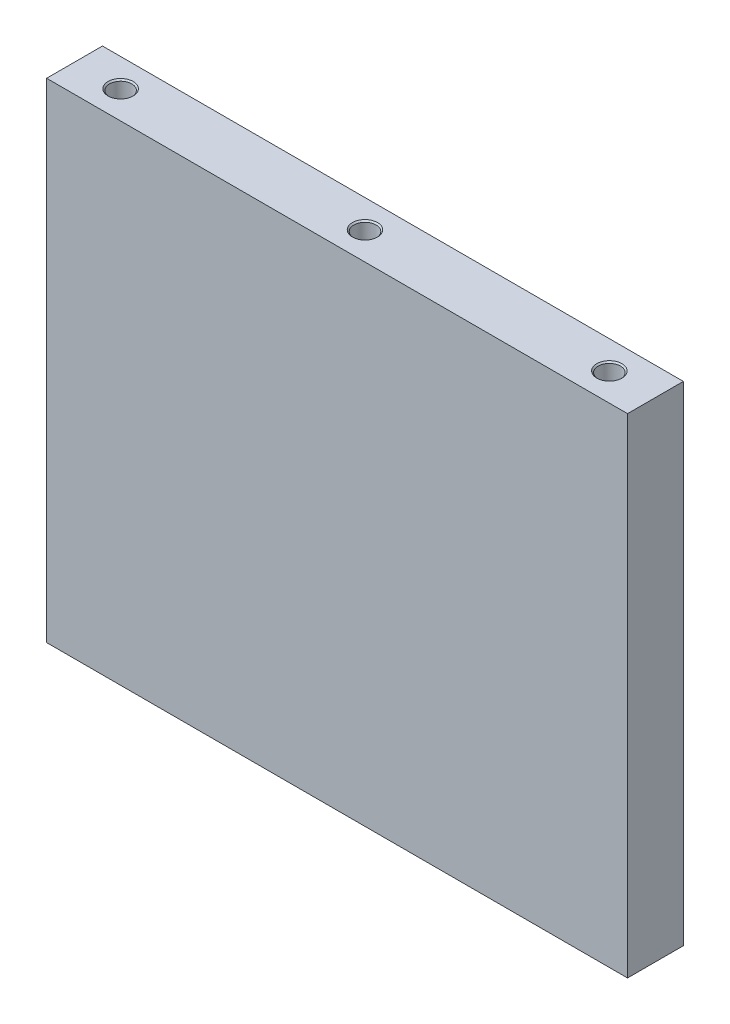
from build123d import *

# Parameters (mm, degrees)
SKETCH1_W           = 208
SKETCH1_H           = 20
BOSS_EXTRUDE1_DEPTH = 175
SKETCH2_R           = 4
CUT_EXTRUDE1_DEPTH  = 12
CHAMFER1_SIZE       = 0.5


with BuildPart() as part:
    # Sketch1 → Boss-Extrude1 (new body)
    with BuildSketch(Plane(origin=(0, 0, -58), x_dir=(1, 0, 0), z_dir=(0, 1, 0))):
        with Locations((0, -58)):
            Rectangle(SKETCH1_W, SKETCH1_H)
    extrude(amount=BOSS_EXTRUDE1_DEPTH)

    # Sketch2 → Cut-Extrude1 (cut)
    with BuildSketch(Plane(origin=(0, 175, 0), x_dir=(1, 0, 0), z_dir=(0, 1, 0))):
        Circle(SKETCH2_R)
        with Locations((-87.5, 0)):
            Circle(SKETCH2_R)
        with Locations((87.5, 0)):
            Circle(SKETCH2_R)
    cut_extrude1 = extrude(amount=-CUT_EXTRUDE1_DEPTH, mode=Mode.SUBTRACT)

    # Mirror6: Cut-Extrude1 across plane
    add(cut_extrude1.mirror(Plane.ZX.offset(87.5)), mode=Mode.SUBTRACT)

    # Chamfer1
    chamfer1_edges = [part.edges().sort_by_distance(p)[0] for p in [
        (83.5, 175, 0),
        (-91.5, 175, 0),
        (-4, 175, 0),
        (83.5, 0, 0),
        (-91.5, 0, 0),
        (-4, 0, 0),
    ]]
    chamfer(chamfer1_edges, length=CHAMFER1_SIZE)


solid = part.part
